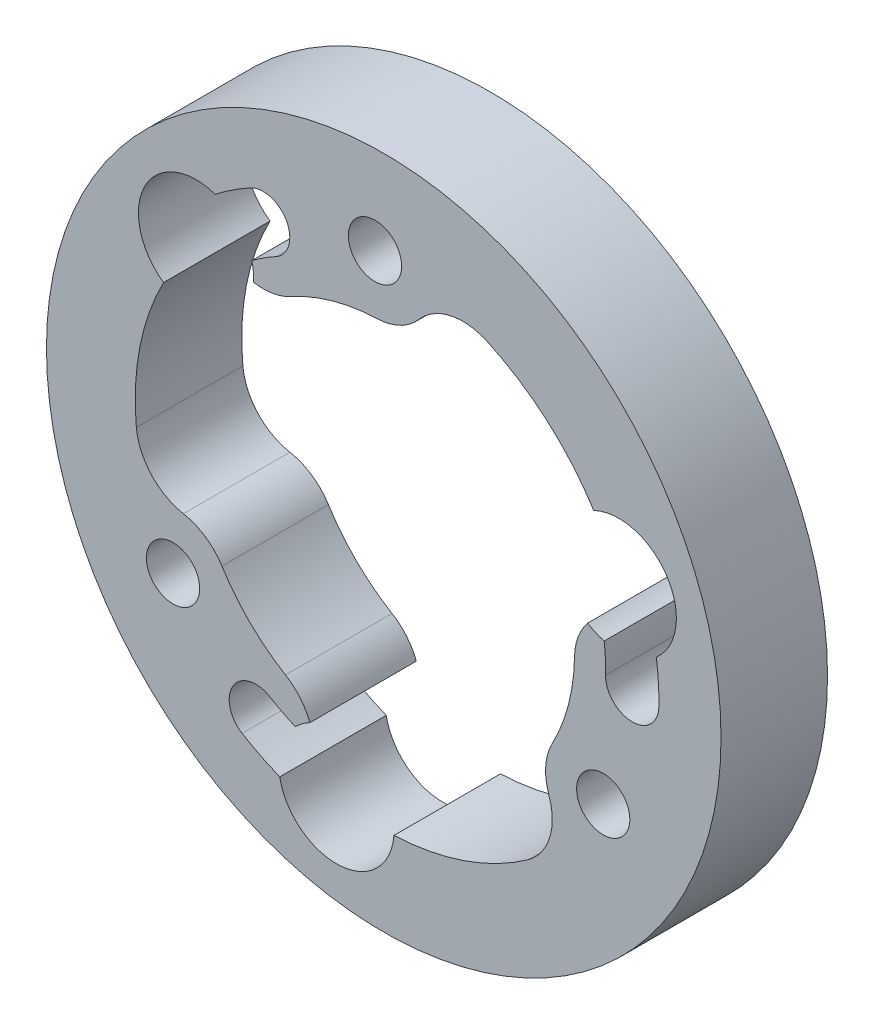
from build123d import *

# Parameters (mm, degrees)
ESQUISSE1_R        = 19
ESQUISSE1_R_2      = 1.5
BOSS_EXTRU_2_DEPTH = 6


with BuildPart() as part:
    # Esquisse1 → Boss.-Extru.2 (new body)
    with BuildSketch(Plane.XY):
        Circle(ESQUISSE1_R)
        with Locations((-0.493805045, 13.991288596)):
            Circle(ESQUISSE1_R_2, mode=Mode.SUBTRACT)
        with Locations((12.363713879, -6.567996584)):
            Circle(ESQUISSE1_R_2, mode=Mode.SUBTRACT)
        with Locations((-11.869908833, -7.423292012)):
            Circle(ESQUISSE1_R_2, mode=Mode.SUBTRACT)
        with BuildLine():
            ThreePointArc((-0.379171731, 10.743310886), (0.922172629, 11.065966866), (1.982535482, 11.886475637))
            ThreePointArc((1.982535482, 11.886475637), (3.751818189, 12.953817976), (5.806908291, 12.738909534))
            ThreePointArc((5.806908291, 12.738909534), (9.198945104, 10.553644346), (11.826845368, 7.491710662))
            ThreePointArc((11.826845368, 7.491710662), (15.95449234, 6.343310094), (15.356979769, 2.100755188))
            ThreePointArc((15.356979769, 2.100755188), (15.472630931, 0.920701949), (15.497738971, -0.264739076))
            ThreePointArc((15.497738971, -0.264739076), (13.97233787, -1.738900356), (12.49817659, -0.213499254))
            ThreePointArc((12.49817659, -0.213499254), (12.485444687, 0.603051388), (12.419421545, 1.417028044))
            ThreePointArc((12.419421545, 1.417028044), (11.936947212, 1.58360629), (11.486503898, 1.823670062))
            ThreePointArc((11.486503898, 1.823670062), (10.947627516, 0.882480264), (10.748431867, -0.183609359))
            ThreePointArc((10.748431867, -0.183609359), (10.408589086, -2.687707806), (9.493566014, -5.043283091))
            ThreePointArc((9.493566014, -5.043283091), (9.122322109, -6.331608356), (9.302722122, -7.66016391))
            ThreePointArc((9.302722122, -7.66016391), (9.342426349, -9.72607885), (8.128765127, -11.398384864))
            ThreePointArc((8.128765127, -11.398384864), (4.540251554, -13.243342321), (0.574589068, -13.988203866))
            ThreePointArc((0.574589068, -13.988203866), (-2.483778485, -16.988650718), (-5.859182525, -14.3499122))
            ThreePointArc((-5.859182525, -14.3499122), (-6.938964188, -13.860042424), (-7.97814025, -13.289066113))
            ThreePointArc((-7.97814025, -13.289066113), (-8.492100818, -11.230949368), (-6.433984073, -10.7169888))
            ThreePointArc((-6.433984073, -10.7169888), (-5.720464522, -11.11423797), (-4.982528488, -11.464048581))
            ThreePointArc((-4.982528488, -11.464048581), (-4.597030329, -11.129502674), (-4.163907347, -10.859439207))
            ThreePointArc((-4.163907347, -10.859439207), (-4.709563431, -9.922163672), (-5.533226303, -9.216610368))
            ThreePointArc((-5.533226303, -9.216610368), (-7.53191778, -7.670248663), (-9.114394283, -5.700027795))
            ThreePointArc((-9.114394283, -5.700027795), (-10.044494737, -4.73435851), (-11.285257604, -4.226311727))
            ThreePointArc((-11.285257604, -4.226311727), (-13.094244538, -3.227739126), (-13.935673418, -1.34052467))
            ThreePointArc((-13.935673418, -1.34052467), (-13.739196658, 2.689697975), (-12.401434435, 6.496493204))
            ThreePointArc((-12.401434435, 6.496493204), (-13.470713855, 10.645340625), (-9.497797245, 12.249157012))
            ThreePointArc((-9.497797245, 12.249157012), (-8.533666743, 12.939340475), (-7.519598721, 13.553805188))
            ThreePointArc((-7.519598721, 13.553805188), (-5.480237052, 12.969849724), (-6.064192517, 10.930488055))
            ThreePointArc((-6.064192517, 10.930488055), (-6.764980165, 10.511186582), (-7.436893057, 10.047020536))
            ThreePointArc((-7.436893057, 10.047020536), (-7.339916883, 9.545896384), (-7.32259655, 9.035769145))
            ThreePointArc((-7.32259655, 9.035769145), (-6.238064085, 9.039683408), (-5.215205564, 9.400219727))
            ThreePointArc((-5.215205564, 9.400219727), (-2.876671305, 10.357956468), (-0.379171731, 10.743310886))
        make_face(mode=Mode.SUBTRACT)
    extrude(amount=BOSS_EXTRU_2_DEPTH)


solid = part.part
